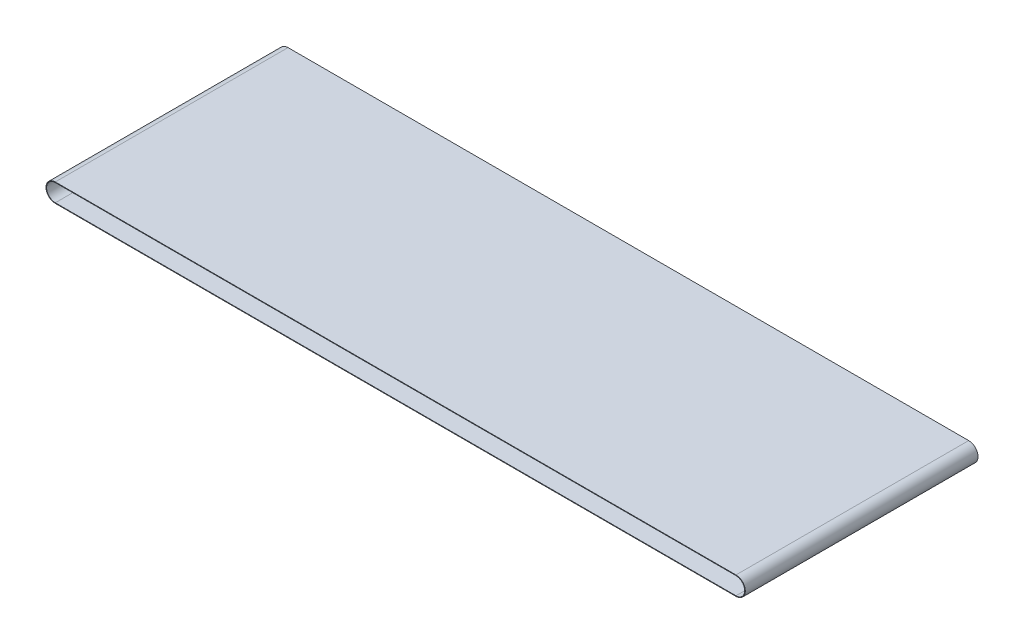
from build123d import *

# Parameters (mm, degrees)
EXTRUDE_THIN1_DEPTH = 200


with BuildPart() as part:
    # Sketch1 → Extrude-Thin1 (new body, symmetric)
    with BuildSketch(Plane.XY):
        with BuildLine():
            Line((585, -31), (-585, -31))
            ThreePointArc((-585, -31), (-601, -15), (-585, 1))
            Line((-585, 1), (585, 1))
            ThreePointArc((585, 1), (601, -15), (585, -31))
        make_face()
        with BuildLine():
            Line((585, -30), (-585, -30))
            ThreePointArc((-585, -30), (-600, -15), (-585, 0))
            Line((-585, 0), (585, 0))
            ThreePointArc((585, 0), (600, -15), (585, -30))
        make_face(mode=Mode.SUBTRACT)
    extrude(amount=EXTRUDE_THIN1_DEPTH, both=True)


solid = part.part
